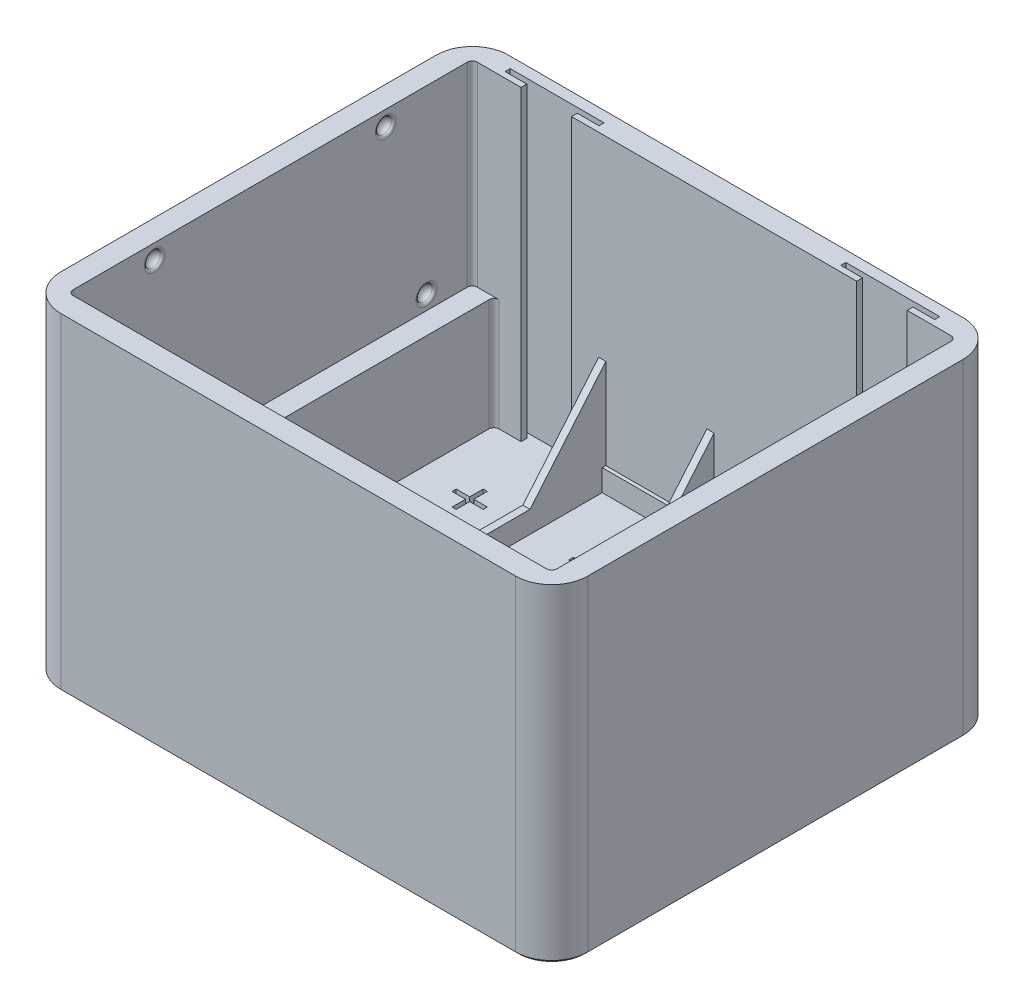
from build123d import *

# Parameters (mm, degrees)
SKETCH1_W               = 67
SKETCH1_H               = 62
BOSS_EXTRUDE1_DEPTH     = 3
SKETCH2_W               = 67
SKETCH2_H               = 62
SKETCH2_W_2             = 61
SKETCH2_H_2             = 56
SKETCH2_W_3             = 1
BOSS_EXTRUDE2_DEPTH     = 15.5
CUT_EXTRUDE1_REACH      = 63.266
SKETCH5_W               = 62
SKETCH5_H               = 18.5
BOSS_EXTRUDE4_DEPTH     = 3
SKETCH17_W              = 62
SKETCH17_H              = 18.5
BOSS_EXTRUDE7_DEPTH     = 3
SKETCH7_W               = 73
SKETCH7_H               = 62
SKETCH7_W_2             = 67
SKETCH7_H_2             = 56
BOSS_EXTRUDE5_DEPTH     = 27
SKETCH10_W              = 2.442307692
SKETCH10_H              = 0.651282052
CUT_EXTRUDE4_DEPTH      = 1
SKETCH11_W              = 1
SKETCH11_H              = 0.5
CUT_EXTRUDE5_DEPTH      = 55.974994316
CUT_EXTRUDE5_DEPTH_BACK = 15.5
FILLET1_R               = 5
FILLET2_R               = 0.7
CHAMFER2_SIZE           = 0.4
SKETCH16_W              = 30
SKETCH16_H              = 0.5
BOSS_EXTRUDE6_DEPTH     = 3
FILLET3_R               = 0.4
FILLET4_R               = 0.4


with BuildPart() as part:
    # Sketch1 → Boss-Extrude1 (new body)
    with BuildSketch(Plane(origin=(0, 0, 0), x_dir=(1, 0, 0), z_dir=(0, 1, 0))):
        Rectangle(SKETCH1_W, SKETCH1_H)
    extrude(amount=BOSS_EXTRUDE1_DEPTH)

    # Sketch2 → Boss-Extrude2 (add)
    with BuildSketch(Plane(origin=(0, 3, 0), x_dir=(1, 0, 0), z_dir=(0, 1, 0))):
        Rectangle(SKETCH2_W, SKETCH2_H)
        Rectangle(SKETCH2_W_2, SKETCH2_H_2, mode=Mode.SUBTRACT)
        with Locations((-15.5, 0)):
            Rectangle(SKETCH2_W_3, SKETCH2_H_2)
        Rectangle(SKETCH2_W_3, SKETCH2_H_2)
        with Locations((15.5, 0)):
            Rectangle(SKETCH2_W_3, SKETCH2_H_2)
    extrude(amount=BOSS_EXTRUDE2_DEPTH)

    # Cut-Extrude1: up to this face of the body (flat: up to its plane)
    cut_extrude1_end = Plane(part.part.faces().sort_by_distance((16, 10.75, 0))[0])
    # Sketch4 → Cut-Extrude1 (cut, up to the picked face)
    with BuildSketch(Plane.ZY.offset(16), mode=Mode.PRIVATE) as cut_extrude1_sk1:
        Polygon((-28, 18.5), (-17.5, 6), (17.5, 6), (28, 18.5), align=None)
    cut_extrude1_tool1 = split(extrude(cut_extrude1_sk1.sketch, amount=-CUT_EXTRUDE1_REACH, mode=Mode.PRIVATE), bisect_by=cut_extrude1_end, keep=Keep.BOTH, mode=Mode.PRIVATE)
    add(cut_extrude1_tool1.solids().sort_by(Axis((-16, 12.730769, 0), (1, 0, 0)))[0], mode=Mode.SUBTRACT)

    # Sketch5 → Boss-Extrude4 (add)
    with BuildSketch(Plane.ZY.offset(33.5)):
        with Locations((0, 9.25)):
            Rectangle(SKETCH5_W, SKETCH5_H)
    extrude(amount=BOSS_EXTRUDE4_DEPTH)

    # Sketch17 → Boss-Extrude7 (add)
    with BuildSketch(Plane(origin=(33.5, 0, 0), x_dir=(0, 0, -1), z_dir=(1, 0, 0))):
        with Locations((0, 9.25)):
            Rectangle(SKETCH17_W, SKETCH17_H)
    extrude(amount=BOSS_EXTRUDE7_DEPTH)

    # Sketch7 → Boss-Extrude5 (add)
    with BuildSketch(Plane(origin=(0, 18.5, 0), x_dir=(1, 0, 0), z_dir=(0, 1, 0))):
        Rectangle(SKETCH7_W, SKETCH7_H)
        Rectangle(SKETCH7_W_2, SKETCH7_H_2, mode=Mode.SUBTRACT)
    extrude(amount=BOSS_EXTRUDE5_DEPTH)

    # Sketch10 → Cut-Extrude4 (cut)
    with BuildSketch(Plane(origin=(0, 3, 0), x_dir=(1, 0, 0), z_dir=(0, 1, 0))):
        Polygon((-23.67846909, 17.818834848), (-23.67846909, 19.691270745), (-23.108597295, 19.691270745), (-23.108597295, 17.818834848), (-21.236161397, 17.818834848), (-21.236161397, 17.248963053), (-23.108597295, 17.248963053), (-23.108597295, 15.376527155), (-23.67846909, 15.376527155), (-23.67846909, 17.248963053), (-25.550904987, 17.248963053), (-25.550904987, 17.818834848), align=None)
        with Locations((-23.51260545, -17.350602641)):
            Rectangle(SKETCH10_W, SKETCH10_H)
        with Locations((-8.027527769, 17.417895934)):
            Rectangle(SKETCH10_W, SKETCH10_H)
        Polygon((-8.179258882, -17.106750317), (-8.179258882, -15.23431442), (-7.609387087, -15.23431442), (-7.609387087, -17.106750317), (-5.736951189, -17.106750317), (-5.736951189, -17.676622112), (-7.609387087, -17.676622112), (-7.609387087, -19.549058009), (-8.179258882, -19.549058009), (-8.179258882, -17.676622112), (-10.051694779, -17.676622112), (-10.051694779, -17.106750317), align=None)
        Polygon((8.157746473, 17.818834848), (8.157746473, 19.691270745), (8.727618268, 19.691270745), (8.727618268, 17.818834848), (10.600054165, 17.818834848), (10.600054165, 17.248963053), (8.727618268, 17.248963053), (8.727618268, 15.376527155), (8.157746473, 15.376527155), (8.157746473, 17.248963053), (6.285310575, 17.248963053), (6.285310575, 17.818834848), align=None)
        with Locations((8.414201979, -17.350602641)):
            Rectangle(SKETCH10_W, SKETCH10_H)
        with Locations((24.594120743, 17.417895934)):
            Rectangle(SKETCH10_W, SKETCH10_H)
        Polygon((24.494751827, -17.106750317), (24.494751827, -15.23431442), (25.064623622, -15.23431442), (25.064623622, -17.106750317), (26.93705952, -17.106750317), (26.93705952, -17.676622112), (25.064623622, -17.676622112), (25.064623622, -19.549058009), (24.494751827, -19.549058009), (24.494751827, -17.676622112), (22.62231593, -17.676622112), (22.62231593, -17.106750317), align=None)
    extrude(amount=-CUT_EXTRUDE4_DEPTH, mode=Mode.SUBTRACT)

    # Sketch11 → Cut-Extrude5 (cut, two sides)
    with BuildSketch(Plane(origin=(0, 18.5, 0), x_dir=(1, 0, 0), z_dir=(0, 1, 0))) as cut_extrude5_sk:
        with Locations((-15.5, -27.75)):
            Rectangle(SKETCH11_W, SKETCH11_H)
        with Locations((0, 27.75)):
            Rectangle(SKETCH11_W, SKETCH11_H)
        with Locations((15.5, -27.75)):
            Rectangle(SKETCH11_W, SKETCH11_H)
        Polygon((-29.75, 28.8), (-26.75, 28.8), (-26.75, 28), (-19.75, 28), (-19.75, 28.8), (-16.75, 28.8), (-16.75, 29.5), (-29.75, 29.5), align=None)
        Polygon((16.75, 28.8), (16.75, 29.5), (29.75, 29.5), (29.75, 28.8), (26.75, 28.8), (26.75, 28), (19.75, 28), (19.75, 28.8), align=None)
    extrude(amount=CUT_EXTRUDE5_DEPTH, mode=Mode.SUBTRACT)
    extrude(cut_extrude5_sk.sketch, amount=-CUT_EXTRUDE5_DEPTH_BACK, mode=Mode.SUBTRACT)

    # Fillet1
    fillet1_edges = [part.edges().sort_by_distance(p)[0] for p in [
        (-36.5, 22.75, -31),
        (-36.5, 22.75, 31),
        (36.5, 22.75, 31),
        (36.5, 22.75, -31),
    ]]
    fillet(fillet1_edges, radius=FILLET1_R)

    # Fillet2
    fillet2_edges = [part.edges().sort_by_distance(p)[0] for p in [
        (-33.5, 32, 28),
        (33.5, 32, 28),
        (33.5, 32, -28),
        (-33.5, 32, -28),
        (-30.5, 10.75, 28),
        (-30.5, 10.75, -28),
        (30.5, 10.75, -28),
        (30.5, 10.75, 28),
    ]]
    fillet(fillet2_edges, radius=FILLET2_R)

    # Chamfer2
    chamfer2_edges = [part.edges().sort_by_distance(p)[0] for p in [
        (36.5, 0, 0),
        (0, 0, -31),
        (0, 0, 31),
        (-36.5, 0, 0),
        (-35.035533906, 0, -29.535533906),
        (-35.035533906, 0, 29.535533906),
        (35.035533906, 0, -29.535533906),
        (35.035533906, 0, 29.535533906),
    ]]
    chamfer(chamfer2_edges, length=CHAMFER2_SIZE)

    # Sketch16 → Boss-Extrude6 (add)
    with BuildSketch(Plane(origin=(0, 3, 0), x_dir=(1, 0, 0), z_dir=(0, 1, 0))):
        with Locations((0, 27.75)):
            Rectangle(SKETCH16_W, SKETCH16_H)
    extrude(amount=BOSS_EXTRUDE6_DEPTH)

    # Sketch19 → Cut-Revolve1 (revolve, cut)
    with BuildSketch(Plane(origin=(0, 20.5, 0), x_dir=(1, 0, 0), z_dir=(0, 1, 0))):
        with BuildLine():
            Line((33.5, -20.55), (33.5, -21.65))
            Line((33.5, -21.65), (34.6, -21.65))
            ThreePointArc((34.6, -21.65), (34.277817459, -20.872182541), (33.5, -20.55))
        make_face()
    cut_revolve1 = revolve(axis=Axis((33.5, 20.5, 21.65), (1, 0, 0)), mode=Mode.SUBTRACT)

    # Mirror1: Cut-Revolve1 across plane
    add(cut_revolve1.mirror(Plane.XY), mode=Mode.SUBTRACT)

    # Mirror2: Cut-Revolve1 across plane
    add(cut_revolve1.mirror(Plane(origin=(0, 0, 0), x_dir=(0, 0, 1), z_dir=(1, 0, 0))), mode=Mode.SUBTRACT)

    # Mirror2 copy 1 sketch → Mirror2 copy 1 (revolve, cut)
    with BuildSketch(Plane(origin=(0, 20.5, 0), x_dir=(-1, 0, 0), z_dir=(0, 1, 0))):
        with BuildLine():
            Line((33.5, -20.55), (33.5, -21.65))
            Line((33.5, -21.65), (34.6, -21.65))
            ThreePointArc((34.6, -21.65), (34.277817459, -20.872182541), (33.5, -20.55))
        make_face()
    revolve(axis=Axis((-33.5, 20.5, -21.65), (-1, 0, 0)), mode=Mode.SUBTRACT)

    # Fillet3
    fillet3_edges = [part.edges().sort_by_distance(p)[0] for p in [
        (33.5, 20.5, 22.75),
        (33.5, 20.5, -22.75),
        (-33.5, 20.5, -22.75),
        (-33.5, 20.5, 22.75),
    ]]
    fillet(fillet3_edges, radius=FILLET3_R)

    # Sketch20 → Cut-Revolve2 (revolve, cut)
    with BuildSketch(Plane(origin=(0, 43.4, 0), x_dir=(1, 0, 0), z_dir=(0, 1, 0)), mode=Mode.PRIVATE) as cut_revolve2_sk:
        with BuildLine():
            ThreePointArc((-34.6, 16), (-34.277817459, 16.777817459), (-33.5, 17.1))
            Line((-33.5, 17.1), (-33.5, 16))
            Line((-33.5, 16), (-34.6, 16))
        make_face()
    cut_revolve2 = revolve(cut_revolve2_sk.sketch.rotate(Axis((-33.5, 43.4, -16), (-1, 0, 0)), 180), axis=Axis((-33.5, 43.4, -16), (-1, 0, 0)), mode=Mode.SUBTRACT)

    # Mirror3: Cut-Revolve2 across plane
    add(cut_revolve2.mirror(Plane.XY), mode=Mode.SUBTRACT)

    # Mirror4: Cut-Revolve2 across plane
    add(cut_revolve2.mirror(Plane(origin=(0, 0, 0), x_dir=(0, 0, 1), z_dir=(1, 0, 0))), mode=Mode.SUBTRACT)

    # Mirror4 copy 1 sketch → Mirror4 copy 1 (revolve, cut)
    with BuildSketch(Plane(origin=(0, 43.4, 0), x_dir=(-1, 0, 0), z_dir=(0, 1, 0))):
        with BuildLine():
            ThreePointArc((-34.6, 16), (-34.277817459, 16.777817459), (-33.5, 17.1))
            Line((-33.5, 17.1), (-33.5, 16))
            Line((-33.5, 16), (-34.6, 16))
        make_face()
    revolve(axis=Axis((33.5, 43.4, 16), (1, 0, 0)), mode=Mode.SUBTRACT)

    # Fillet4
    fillet4_edges = [part.edges().sort_by_distance(p)[0] for p in [
        (-33.5, 43.4, -17.1),
        (-33.5, 43.4, 17.1),
        (33.5, 43.4, -17.1),
        (33.5, 43.4, 14.9),
    ]]
    fillet(fillet4_edges, radius=FILLET4_R)


solid = part.part
